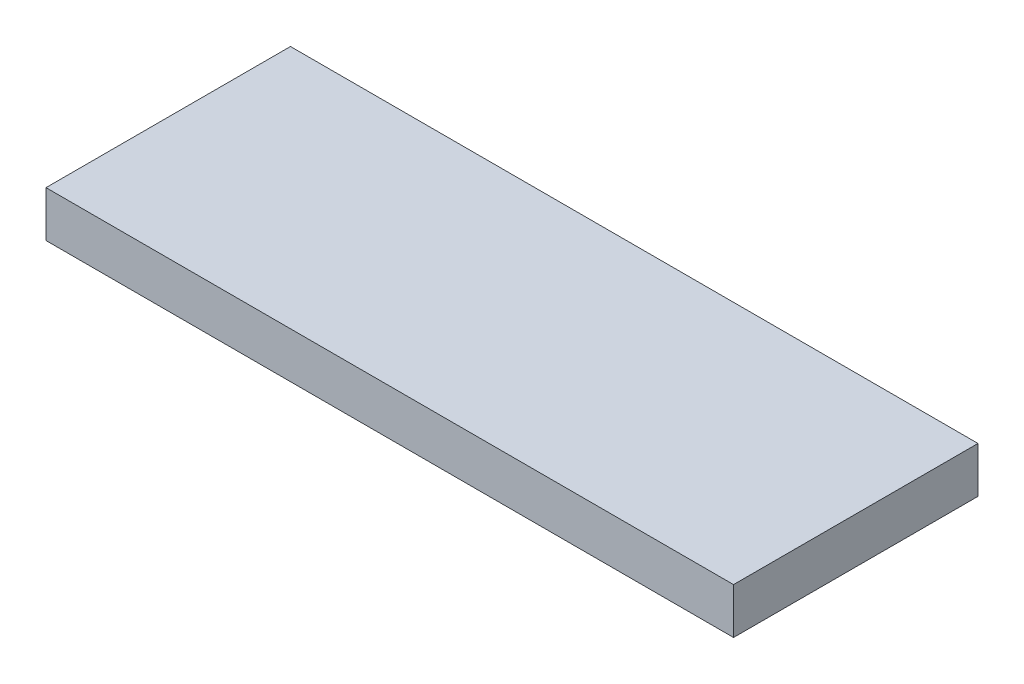
from build123d import *

# Parameters (mm, degrees)
SKETCH1_W           = 285.75
SKETCH1_H           = 101.6
BOSS_EXTRUDE1_DEPTH = 19.05


with BuildPart() as part:
    # Sketch1 → Boss-Extrude1 (new body)
    with BuildSketch(Plane(origin=(0, 0, 0), x_dir=(1, 0, 0), z_dir=(0, 1, 0))):
        with Locations((49.989118182, -13.127708602)):
            Rectangle(SKETCH1_W, SKETCH1_H)
    extrude(amount=BOSS_EXTRUDE1_DEPTH)


solid = part.part
